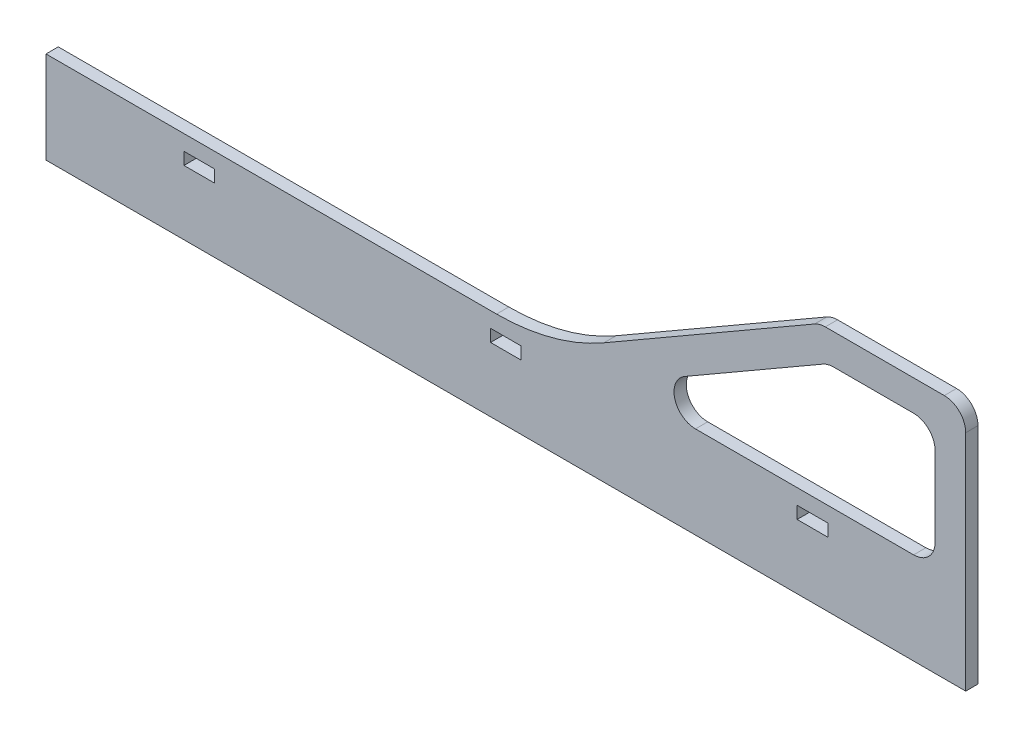
from build123d import *

# Parameters (mm, degrees)
SCHIZZO1_W                   = 10
SCHIZZO1_H                   = 4
ESTRUSIONE_ESTRUSIONE3_DEPTH = 4


with BuildPart() as part:
    # Schizzo1 → Estrusione-Estrusione3 (new body)
    with BuildSketch(Plane.XY):
        with BuildLine():
            Line((400, 30), (400, 0))
            Line((400, 0), (700, 0))
            Line((700, 0), (700, 30))
            Line((700, 30), (700, 73))
            ThreePointArc((700, 73), (697.949747468, 77.949747468), (693, 80))
            Line((693, 80), (654.193736081, 80))
            ThreePointArc((654.193736081, 80), (652.382002765, 79.761480784), (650.693736081, 79.062177826))
            Line((650.693736081, 79.062177826), (581.959107885, 39.378221735))
            ThreePointArc((581.959107885, 39.378221735), (565.076441043, 32.38519216), (546.959107885, 30))
            Line((546.959107885, 30), (400, 30))
        make_face()
        with Locations((450, 23)):
            Rectangle(SCHIZZO1_W, SCHIZZO1_H, mode=Mode.SUBTRACT)
        with Locations((550, 23)):
            Rectangle(SCHIZZO1_W, SCHIZZO1_H, mode=Mode.SUBTRACT)
        with Locations((650, 23)):
            Rectangle(SCHIZZO1_W, SCHIZZO1_H, mode=Mode.SUBTRACT)
        with BuildLine():
            Line((690, 63), (690, 37))
            ThreePointArc((690, 37), (687.949747468, 32.050252532), (683, 30))
            Line((683, 30), (611.839907009, 30))
            ThreePointArc((611.839907009, 30), (605.078426225, 35.188266684), (608.339907009, 43.062177826))
            Line((608.339907009, 43.062177826), (653.373228005, 69.062177826))
            ThreePointArc((653.373228005, 69.062177826), (655.06149469, 69.761480784), (656.873228005, 70))
            Line((656.873228005, 70), (683, 70))
            ThreePointArc((683, 70), (687.949747468, 67.949747468), (690, 63))
        make_face(mode=Mode.SUBTRACT)
    extrude(amount=ESTRUSIONE_ESTRUSIONE3_DEPTH)


solid = part.part
